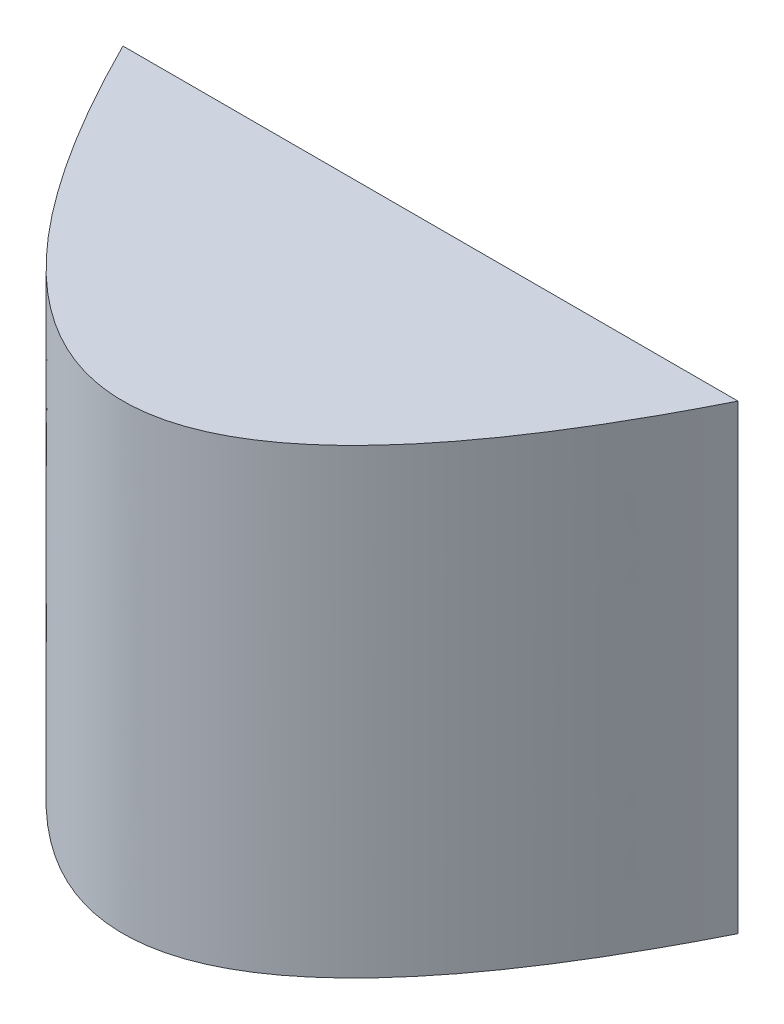
from build123d import *

# Parameters (mm, degrees)
BOSS_EXTRUDE1_DEPTH = 300


with BuildPart() as part:
    # Sketch1 → Boss-Extrude1 (new body)
    with BuildSketch(Plane(origin=(0, 0, 0), x_dir=(1, 0, 0), z_dir=(0, 1, 0))):
        with BuildLine():
            Line((-200, 1e-09), (200, 1e-09))
            add(Edge.make_bspline(
                [(-200, 1e-09), (0, -400.000000001), (200, 1e-09)],
                knots=[0.056028396, 0.056028396, 0.056028396, 0.943971604, 0.943971604, 0.943971604], degree=2))
        make_face()
    extrude(amount=BOSS_EXTRUDE1_DEPTH)


solid = part.part
